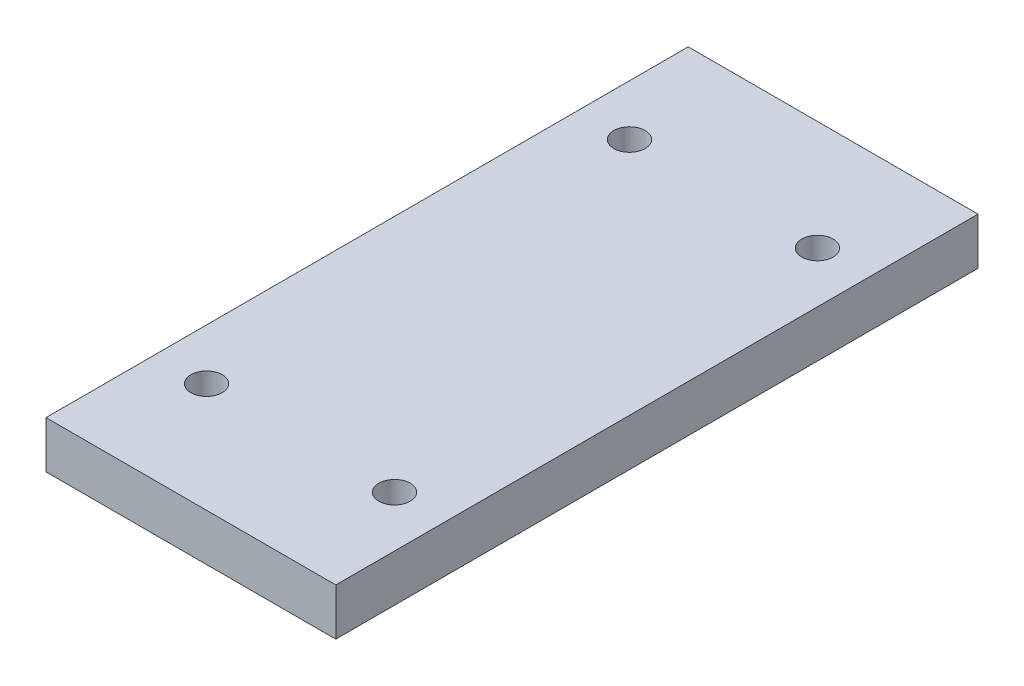
from build123d import *

# Parameters (mm, degrees)
CROQUIS1_W              = 18.5
CROQUIS1_H              = 41
CROQUIS1_R              = 0.999999878
CROQUIS1_R_2            = 1.000000038
CROQUIS1_R_3            = 0.99976782
CROQUIS1_R_4            = 0.999999972
SALIENTE_EXTRUIR1_DEPTH = 3


with BuildPart() as part:
    # Croquis1 → Saliente-Extruir1 (new body)
    with BuildSketch(Plane(origin=(0, 0, 0), x_dir=(1, 0, 0), z_dir=(0, 1, 0))):
        with Locations((2.995594555, -0.561673979)):
            Rectangle(CROQUIS1_W, CROQUIS1_H)
        with Locations((-3.004405388, 12.938325994)):
            Circle(CROQUIS1_R, mode=Mode.SUBTRACT)
        with Locations((8.995594645, 12.938325812)):
            Circle(CROQUIS1_R_2, mode=Mode.SUBTRACT)
        with Locations((-3.004013612, -14.061723516)):
            Circle(CROQUIS1_R_3, mode=Mode.SUBTRACT)
        with Locations((8.9955946, -14.061674139)):
            Circle(CROQUIS1_R_4, mode=Mode.SUBTRACT)
    extrude(amount=SALIENTE_EXTRUIR1_DEPTH)


solid = part.part
